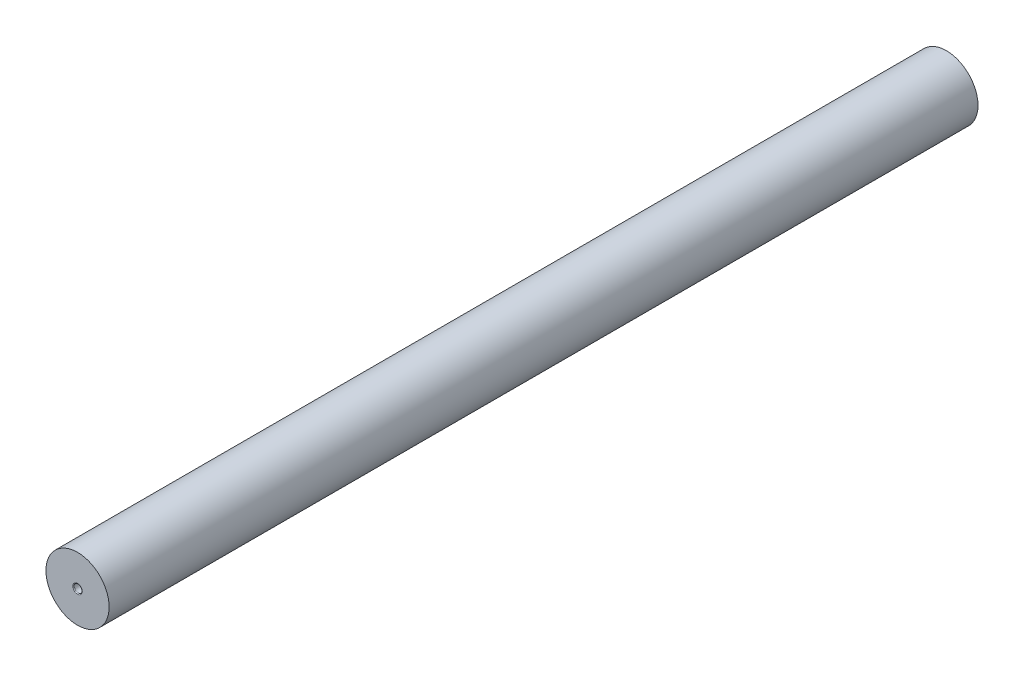
from build123d import *

# Parameters (mm, degrees)
IZIM1_R                     = 4
Y_KSEKLIK_EKSTR_ZYON1_DEPTH = 110
IZIM2_R                     = 0.5
KES_EKSTR_ZYON1_DEPTH       = 5
RADYUS1_R                   = 0.1


with BuildPart() as part:
    # Çizim1 → Yükseklik-Ekstrüzyon1 (new body)
    with BuildSketch(Plane.XY):
        Circle(IZIM1_R)
    extrude(amount=Y_KSEKLIK_EKSTR_ZYON1_DEPTH)

    # Çizim2 → Kes-Ekstrüzyon1 (cut)
    with BuildSketch(Plane.XY.offset(110)):
        Circle(IZIM2_R)
    extrude(amount=-KES_EKSTR_ZYON1_DEPTH, mode=Mode.SUBTRACT)

    # Radyus1
    radyus1_edges = [part.edges().sort_by_distance(p)[0] for p in [
        (-0.5, 0, 110),
    ]]
    fillet(radyus1_edges, radius=RADYUS1_R)


solid = part.part
